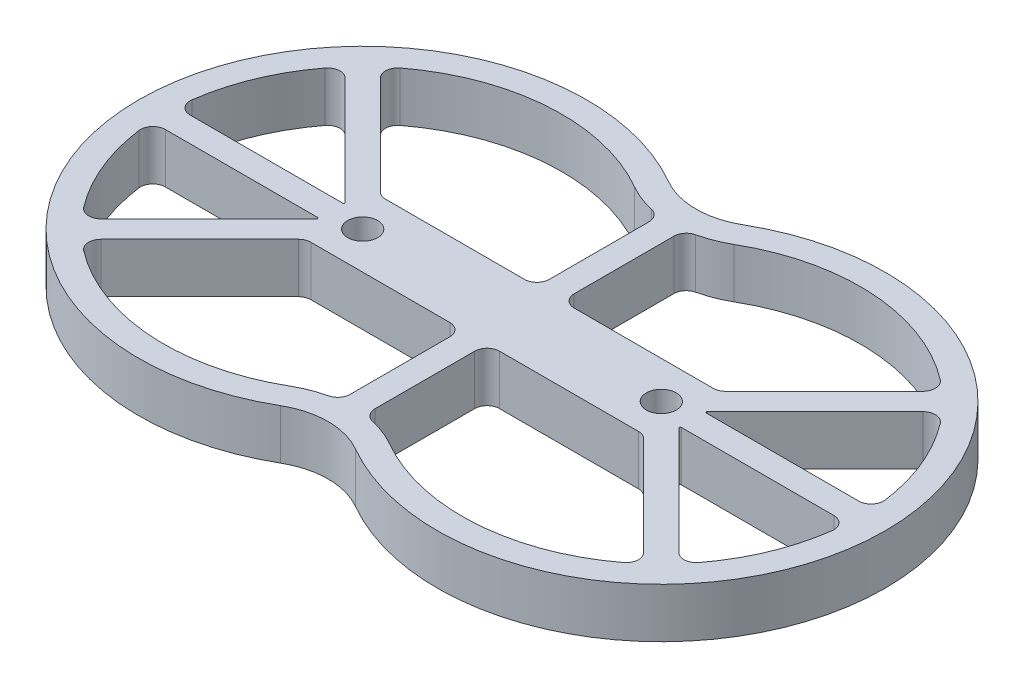
from build123d import *

# Parameters (mm, degrees)
SKETCH2_R           = 6
BOSS_EXTRUDE1_DEPTH = 20


with BuildPart() as part:
    # Sketch2 → Boss-Extrude1 (new body)
    with BuildSketch(Plane(origin=(0, 0, 0), x_dir=(1, 0, 0), z_dir=(0, 1, 0))):
        with BuildLine():
            ThreePointArc((150, 0), (105, 77.942286341), (15, 77.942286341))
            ThreePointArc((15, 77.942286341), (7.764571353, 74.945273665), (0, 73.923048454))
            ThreePointArc((0, 73.923048454), (-7.764571353, 74.945273665), (-15, 77.942286341))
            ThreePointArc((-15, 77.942286341), (-150, 0), (-15, -77.942286341))
            ThreePointArc((-15, -77.942286341), (-7.764571353, -74.945273665), (0, -73.923048454))
            ThreePointArc((0, -73.923048454), (7.764571353, -74.945273665), (15, -77.942286341))
            ThreePointArc((15, -77.942286341), (105, -77.942286341), (150, 0))
        make_face()
        with Locations((60, 0)):
            Circle(SKETCH2_R, mode=Mode.SUBTRACT)
        with Locations((-60, 0)):
            Circle(SKETCH2_R, mode=Mode.SUBTRACT)
        with BuildLine():
            Line((5, 60.048226517), (5, 20))
            ThreePointArc((5, 20), (6.464466094, 16.464466094), (10, 15))
            Line((10, 15), (65.857864376, 15))
            ThreePointArc((65.857864376, 15), (67.771281538, 15.380602337), (69.393398282, 16.464466094))
            Line((69.393398282, 16.464466094), (109.023956198, 56.09502401))
            ThreePointArc((109.023956198, 56.09502401), (110.47724887, 59.964637812), (108.520983778, 63.605928444))
            ThreePointArc((108.520983778, 63.605928444), (65.119211843, 79.836042425), (20, 69.282032303))
            ThreePointArc((20, 69.282032303), (14.607936726, 66.68586026), (8.888888889, 64.923206732))
            ThreePointArc((8.888888889, 64.923206732), (6.0913202, 63.166274339), (5, 60.048226517))
        make_face(mode=Mode.SUBTRACT)
        with BuildLine():
            Line((134.330343737, 5), (73.036753237, 5))
            ThreePointArc((73.036753237, 5), (72.667201424, 5.246926627), (72.753910524, 5.682842712))
            Line((72.753910524, 5.682842712), (116.09502401, 49.023956198))
            ThreePointArc((116.09502401, 49.023956198), (119.964637812, 50.47724887), (123.605928444, 48.520983778))
            ThreePointArc((123.605928444, 48.520983778), (133.910362601, 30.614674589), (139.285699986, 10.666666667))
            ThreePointArc((139.285699986, 10.666666667), (138.094207, 6.708597057), (134.330343737, 5))
        make_face(mode=Mode.SUBTRACT)
        with BuildLine():
            Line((-72.753910524, 5.682842712), (-116.09502401, 49.023956198))
            ThreePointArc((-116.09502401, 49.023956198), (-119.964637812, 50.47724887), (-123.605928444, 48.520983778))
            ThreePointArc((-123.605928444, 48.520983778), (-133.910362601, 30.614674589), (-139.285699986, 10.666666667))
            ThreePointArc((-139.285699986, 10.666666667), (-138.094207, 6.708597057), (-134.330343737, 5))
            Line((-134.330343737, 5), (-73.036753237, 5))
            ThreePointArc((-73.036753237, 5), (-72.667201424, 5.246926627), (-72.753910524, 5.682842712))
        make_face(mode=Mode.SUBTRACT)
        with BuildLine():
            Line((-69.393398282, 16.464466094), (-109.023956198, 56.09502401))
            ThreePointArc((-109.023956198, 56.09502401), (-110.47724887, 59.964637812), (-108.520983778, 63.605928444))
            ThreePointArc((-108.520983778, 63.605928444), (-65.119211843, 79.836042425), (-20, 69.282032303))
            ThreePointArc((-20, 69.282032303), (-14.607936726, 66.68586026), (-8.888888889, 64.923206732))
            ThreePointArc((-8.888888889, 64.923206732), (-6.0913202, 63.166274339), (-5, 60.048226517))
            Line((-5, 60.048226517), (-5, 20))
            ThreePointArc((-5, 20), (-6.464466094, 16.464466094), (-10, 15))
            Line((-10, 15), (-65.857864376, 15))
            ThreePointArc((-65.857864376, 15), (-67.771281538, 15.380602337), (-69.393398282, 16.464466094))
        make_face(mode=Mode.SUBTRACT)
        with BuildLine():
            Line((-5, -60.048226517), (-5, -20))
            ThreePointArc((-5, -20), (-6.464466094, -16.464466094), (-10, -15))
            Line((-10, -15), (-65.857864376, -15))
            ThreePointArc((-65.857864376, -15), (-67.771281538, -15.380602337), (-69.393398282, -16.464466094))
            Line((-69.393398282, -16.464466094), (-109.023956198, -56.09502401))
            ThreePointArc((-109.023956198, -56.09502401), (-110.47724887, -59.964637812), (-108.520983778, -63.605928444))
            ThreePointArc((-108.520983778, -63.605928444), (-65.119211843, -79.836042425), (-20, -69.282032303))
            ThreePointArc((-20, -69.282032303), (-14.607936726, -66.68586026), (-8.888888889, -64.923206732))
            ThreePointArc((-8.888888889, -64.923206732), (-6.0913202, -63.166274339), (-5, -60.048226517))
        make_face(mode=Mode.SUBTRACT)
        with BuildLine():
            Line((-134.330343737, -5), (-73.036753237, -5))
            ThreePointArc((-73.036753237, -5), (-72.667201424, -5.246926627), (-72.753910524, -5.682842712))
            Line((-72.753910524, -5.682842712), (-116.09502401, -49.023956198))
            ThreePointArc((-116.09502401, -49.023956198), (-119.964637812, -50.47724887), (-123.605928444, -48.520983778))
            ThreePointArc((-123.605928444, -48.520983778), (-133.910362601, -30.614674589), (-139.285699986, -10.666666667))
            ThreePointArc((-139.285699986, -10.666666667), (-138.094207, -6.708597057), (-134.330343737, -5))
        make_face(mode=Mode.SUBTRACT)
        with BuildLine():
            Line((72.753910524, -5.682842712), (116.09502401, -49.023956198))
            ThreePointArc((116.09502401, -49.023956198), (119.964637812, -50.47724887), (123.605928444, -48.520983778))
            ThreePointArc((123.605928444, -48.520983778), (133.910362601, -30.614674589), (139.285699986, -10.666666667))
            ThreePointArc((139.285699986, -10.666666667), (138.094207, -6.708597057), (134.330343737, -5))
            Line((134.330343737, -5), (73.036753237, -5))
            ThreePointArc((73.036753237, -5), (72.667201424, -5.246926627), (72.753910524, -5.682842712))
        make_face(mode=Mode.SUBTRACT)
        with BuildLine():
            Line((69.393398282, -16.464466094), (109.023956198, -56.09502401))
            ThreePointArc((109.023956198, -56.09502401), (110.47724887, -59.964637812), (108.520983778, -63.605928444))
            ThreePointArc((108.520983778, -63.605928444), (65.119211843, -79.836042425), (20, -69.282032303))
            ThreePointArc((20, -69.282032303), (14.607936726, -66.68586026), (8.888888889, -64.923206732))
            ThreePointArc((8.888888889, -64.923206732), (6.0913202, -63.166274339), (5, -60.048226517))
            Line((5, -60.048226517), (5, -20))
            ThreePointArc((5, -20), (6.464466094, -16.464466094), (10, -15))
            Line((10, -15), (65.857864376, -15))
            ThreePointArc((65.857864376, -15), (67.771281538, -15.380602337), (69.393398282, -16.464466094))
        make_face(mode=Mode.SUBTRACT)
    extrude(amount=BOSS_EXTRUDE1_DEPTH)


solid = part.part
